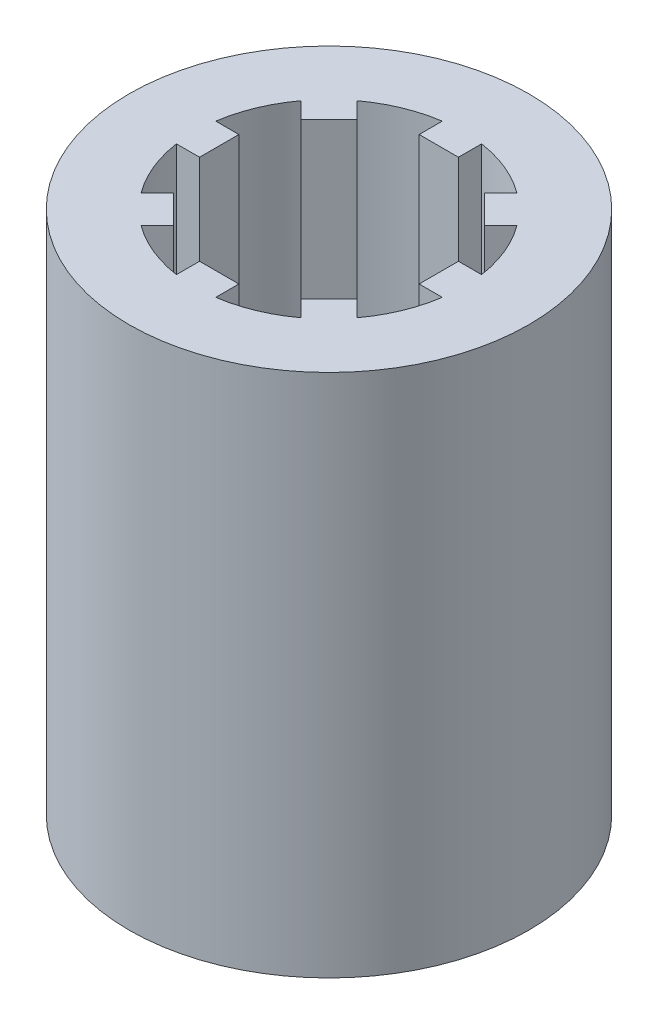
from build123d import *

# Parameters (mm, degrees)
SKETCH3_R           = 19.3675
BOSS_EXTRUDE2_DEPTH = 50.8


with BuildPart() as part:
    # Sketch3 → Boss-Extrude2 (new body)
    with BuildSketch(Plane(origin=(0, 0, 0), x_dir=(1, 0, 0), z_dir=(0, 1, 0))):
        Circle(SKETCH3_R)
        with BuildLine():
            Line((1.905, 12.877355367), (1.905, 10.63625))
            Line((1.905, 10.63625), (-1.905, 10.63625))
            Line((-1.905, 10.63625), (-1.905, 12.877355367))
            ThreePointArc((-1.905, 12.877355367), (-4.981581581, 12.026601814), (-7.758626886, 10.452703722))
            Line((-7.758626886, 10.452703722), (-6.173926083, 8.86800292))
            Line((-6.173926083, 8.86800292), (-8.86800292, 6.173926083))
            Line((-8.86800292, 6.173926083), (-10.452703722, 7.758626886))
            ThreePointArc((-10.452703722, 7.758626886), (-12.026601814, 4.981581581), (-12.877355367, 1.905))
            Line((-12.877355367, 1.905), (-10.63625, 1.905))
            Line((-10.63625, 1.905), (-10.63625, -1.905))
            Line((-10.63625, -1.905), (-12.877355367, -1.905))
            ThreePointArc((-12.877355367, -1.905), (-12.026601814, -4.981581581), (-10.452703722, -7.758626886))
            Line((-10.452703722, -7.758626886), (-8.86800292, -6.173926083))
            Line((-8.86800292, -6.173926083), (-6.173926083, -8.86800292))
            Line((-6.173926083, -8.86800292), (-7.758626886, -10.452703722))
            ThreePointArc((-7.758626886, -10.452703722), (-4.981581581, -12.026601814), (-1.905, -12.877355367))
            Line((-1.905, -12.877355367), (-1.905, -10.63625))
            Line((-1.905, -10.63625), (1.905, -10.63625))
            Line((1.905, -10.63625), (1.905, -12.877355367))
            ThreePointArc((1.905, -12.877355367), (4.981581581, -12.026601814), (7.758626886, -10.452703722))
            Line((7.758626886, -10.452703722), (6.173926083, -8.86800292))
            Line((6.173926083, -8.86800292), (8.86800292, -6.173926083))
            Line((8.86800292, -6.173926083), (10.452703722, -7.758626886))
            ThreePointArc((10.452703722, -7.758626886), (12.026601814, -4.981581581), (12.877355367, -1.905))
            Line((12.877355367, -1.905), (10.63625, -1.905))
            Line((10.63625, -1.905), (10.63625, 1.905))
            Line((10.63625, 1.905), (12.877355367, 1.905))
            ThreePointArc((12.877355367, 1.905), (12.026601814, 4.981581581), (10.452703722, 7.758626886))
            Line((10.452703722, 7.758626886), (8.86800292, 6.173926083))
            Line((8.86800292, 6.173926083), (6.173926083, 8.86800292))
            Line((6.173926083, 8.86800292), (7.758626886, 10.452703722))
            ThreePointArc((7.758626886, 10.452703722), (4.981581581, 12.026601814), (1.905, 12.877355367))
        make_face(mode=Mode.SUBTRACT)
    extrude(amount=BOSS_EXTRUDE2_DEPTH)


solid = part.part
